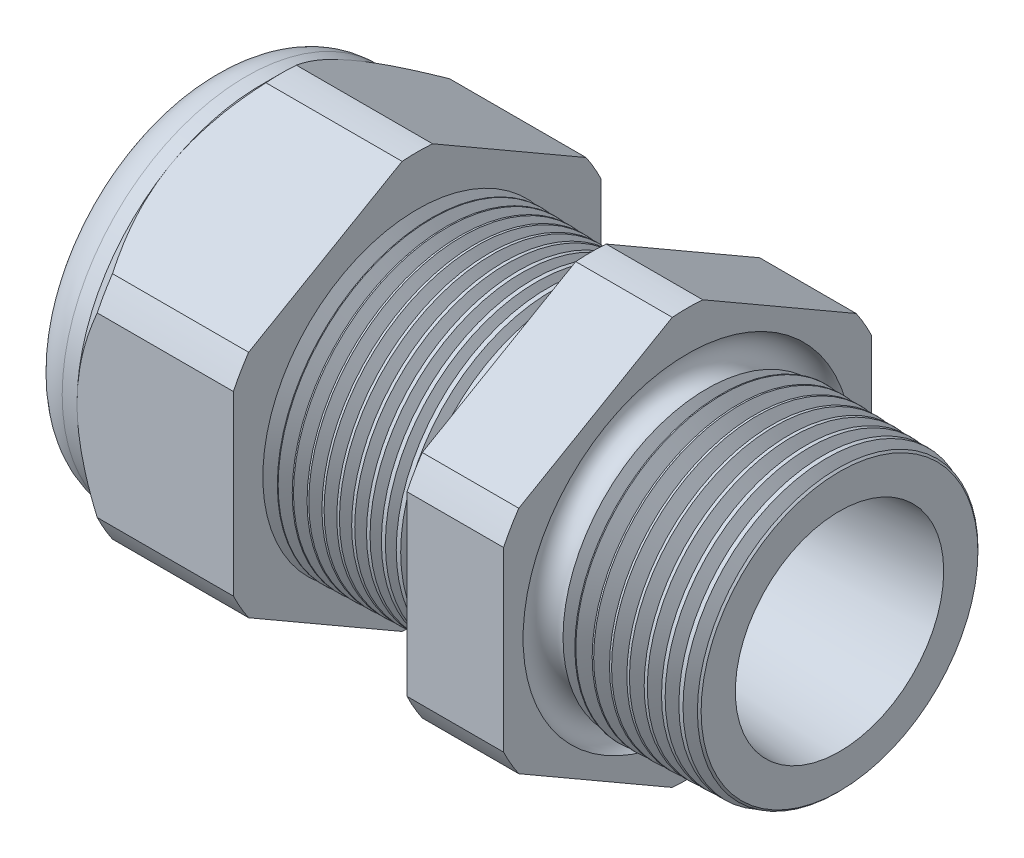
from build123d import *

# Parameters (mm, degrees)
SKETCH12_OUTSIDE_W = 52.712
SKETCH12_OUTSIDE_H = 52.712
CUT_EXTRUDE2_DEPTH = 30.966
FILLET4_R          = 2.032
SKETCH19_OUTSIDE_W = 33.73
SKETCH19_OUTSIDE_H = 35.826
SKETCH19_OUTSIDE_R = 9.525
CUT_EXTRUDE3_DEPTH = 1.999996
CUT_EXTRUDE3_DRAFT = -45
CHAMFER1_SIZE      = 0.260919487
CHAMFER1_SIZE2     = 0.254
SKETCH21_R         = 3.937
PLUG_DEPTH         = 3.81
SKETCH22_R         = 3.683
CUT_EXTRUDE4_DEPTH = 0.508
SKETCH27_R         = 1.524
PLUGHOLES_DEPTH    = 33.258
CIRPATTERN1_COUNT  = 2
LPATTERN1_COUNT    = 12
LPATTERN1_PITCH    = 0.762
LPATTERN2_COUNT    = 9
LPATTERN2_PITCH    = 0.889
SKETCH32_R         = 0.889


with BuildPart() as part:
    # Sketch10 → Revolve2 (revolve)
    with BuildSketch(Plane.XY, mode=Mode.PRIVATE) as revolve2_sk:
        Polygon((-32.766, 3.937), (-21.866, 3.937), (0, 5.396418639), (0, 7.428418639), (-7.874, 7.634606585), (-7.874, 19.05), (-12.874, 19.05), (-12.874, 7.765536193), (-21.866, 8.001), (-21.866, 19.05), (-29.966, 19.05), (-29.966, 9.525), (-32.766, 9.525), align=None)
    revolve(revolve2_sk.sketch.rotate(Axis((0, 0, 0), (-1, 0, 0)), 90), axis=Axis((0, 0, 0), (-1, 0, 0)))  # turned: the seam where the file's is

    # Sketch12 outside → Cut-Extrude2 (cut, through all)
    with BuildSketch(Plane.ZY.offset(29.966)):
        Rectangle(SKETCH12_OUTSIDE_W, SKETCH12_OUTSIDE_H)
        with BuildLine():
            Line((-0.788451287, 10.543310065), (-8.736548713, 5.954473877))
            ThreePointArc((-8.736548713, 5.954473877), (-9.156270088, 5.286375), (-9.525, 4.588836188))
            Line((-9.525, 4.588836188), (-9.525, -4.588836188))
            ThreePointArc((-9.525, -4.588836188), (-9.156270088, -5.286375), (-8.736548713, -5.954473877))
            Line((-8.736548713, -5.954473877), (-0.788451287, -10.543310065))
            ThreePointArc((-0.788451287, -10.543310065), (0, -10.57275), (0.788451287, -10.543310065))
            Line((0.788451287, -10.543310065), (8.736548713, -5.954473877))
            ThreePointArc((8.736548713, -5.954473877), (9.156270088, -5.286375), (9.525, -4.588836188))
            Line((9.525, -4.588836188), (9.525, 4.588836188))
            ThreePointArc((9.525, 4.588836188), (9.156270088, 5.286375), (8.736548713, 5.954473877))
            Line((8.736548713, 5.954473877), (0.788451287, 10.543310065))
            ThreePointArc((0.788451287, 10.543310065), (0, 10.57275), (-0.788451287, 10.543310065))
        make_face(mode=Mode.SUBTRACT)
    extrude(amount=-CUT_EXTRUDE2_DEPTH, mode=Mode.SUBTRACT)

    # Fillet4
    fillet4_edges = [part.edges().sort_by_distance(p)[0] for p in [
        (-32.766, 0, 9.525),
    ]]
    fillet(fillet4_edges, radius=FILLET4_R)


with BuildPart() as cut_extrude3_tool:
    # Sketch19 outside → Cut-Extrude3 (with draft: the straight prism first)
    with BuildSketch(Plane.ZY.offset(29.966)):
        Rectangle(SKETCH19_OUTSIDE_W, SKETCH19_OUTSIDE_H)
        Circle(SKETCH19_OUTSIDE_R, mode=Mode.SUBTRACT)
    extrude(amount=-CUT_EXTRUDE3_DEPTH)
    # Cut-Extrude3: the draft: its side faces are tilted about the plane it starts from
    cut_extrude3_sides = [cut_extrude3_tool.faces().sort_by_distance(p)[0] for p in [
        (-28.966002, -17.913, 0),
        (-28.966002, 0, 16.865),
        (-28.966002, 17.913, 0),
        (-28.966002, 0, -16.865),
        (-28.966002, 0, -9.525),
    ]]
    draft(cut_extrude3_sides, Plane.ZY.offset(29.966), CUT_EXTRUDE3_DRAFT)


with BuildPart() as part_1:
    add(part.part)

    # Cut-Extrude3: cut by cut_extrude3_tool
    add(cut_extrude3_tool.part, mode=Mode.SUBTRACT)

    # Chamfer1
    chamfer1_edges = [part_1.edges().sort_by_distance(p)[0] for p in [
        (0, 0, 7.428418639),
    ]]
    chamfer1_side = [part_1.faces().sort_by_distance(p)[0] for p in [
        (0, 0, 5.606526047),
    ]]
    chamfer(chamfer1_edges, length=CHAMFER1_SIZE, length2=CHAMFER1_SIZE2, reference=chamfer1_side[0])

    # Sketch29 → Cut-Revolve1 (revolve, cut)
    with BuildSketch(Plane.XY, mode=Mode.PRIVATE) as cut_revolve1_sk:
        Polygon((-21.866, 8.001), (-21.133016419, 7.981806149), (-21.516130572, 7.356620673), align=None)
    cut_revolve1 = revolve(cut_revolve1_sk.sketch.rotate(Axis((0, 0, 0), (-1, 0, 0)), 90), axis=Axis((0, 0, 0), (-1, 0, 0)), mode=Mode.SUBTRACT)  # turned: the seam where the file's is

    # LPattern1: Cut-Revolve1 ×12
    with Locations(*[(i * LPATTERN1_PITCH, 0, 0) for i in range(1, LPATTERN1_COUNT)]):
        add(cut_revolve1, mode=Mode.SUBTRACT)

    # Sketch30 → Cut-Revolve2 (revolve, cut)
    with BuildSketch(Plane.XY, mode=Mode.PRIVATE) as cut_revolve2_sk:
        Polygon((-7.874, 7.634606585), (-6.994419703, 7.611573965), (-7.454156686, 6.861351393), align=None)
    cut_revolve2 = revolve(cut_revolve2_sk.sketch.rotate(Axis((0, 0, 0), (-1, 0, 0)), 270), axis=Axis((0, 0, 0), (-1, 0, 0)), mode=Mode.SUBTRACT)  # turned: the seam where the file's is

    # LPattern2: Cut-Revolve2 ×9
    with Locations(*[(i * LPATTERN2_PITCH, 0, 0) for i in range(1, LPATTERN2_COUNT)]):
        add(cut_revolve2, mode=Mode.SUBTRACT)

    # Sketch32 → Cut-Revolve3 (revolve, cut)
    with BuildSketch(Plane.XY, mode=Mode.PRIVATE) as cut_revolve3_sk:
        with Locations((-7.747, 7.634606585)):
            Circle(SKETCH32_R)
    revolve(cut_revolve3_sk.sketch.rotate(Axis((0, 0, 0), (-1, 0, 0)), 270), axis=Axis((0, 0, 0), (-1, 0, 0)), mode=Mode.SUBTRACT)  # turned: the seam where the file's is


with BuildPart() as body_2:
    # Sketch21 → plug (new body)
    with BuildSketch(Plane.ZY.offset(32.766)):
        Circle(SKETCH21_R)
    extrude(amount=-PLUG_DEPTH)

    # Sketch22 → Cut-Extrude4 (cut)
    with BuildSketch(Plane.ZY.offset(32.766)):
        Circle(SKETCH22_R)
    extrude(amount=-CUT_EXTRUDE4_DEPTH, mode=Mode.SUBTRACT)

    # Sketch27 → plugholes (cut, through all)
    with BuildSketch(Plane.ZY.offset(32.258)):
        with Locations((-2.152904, 0)):
            Circle(SKETCH27_R)
    plugholes = extrude(amount=-PLUGHOLES_DEPTH, mode=Mode.SUBTRACT)

    # CirPattern1: plugholes ×2 about axis
    cirpattern1_axis = Axis((0, 0, 0), (1, 0, 0))
    for i in range(1, CIRPATTERN1_COUNT):
        add(plugholes.rotate(cirpattern1_axis, i * 360 / CIRPATTERN1_COUNT), mode=Mode.SUBTRACT)


solid = Compound([part_1.part, body_2.part])
